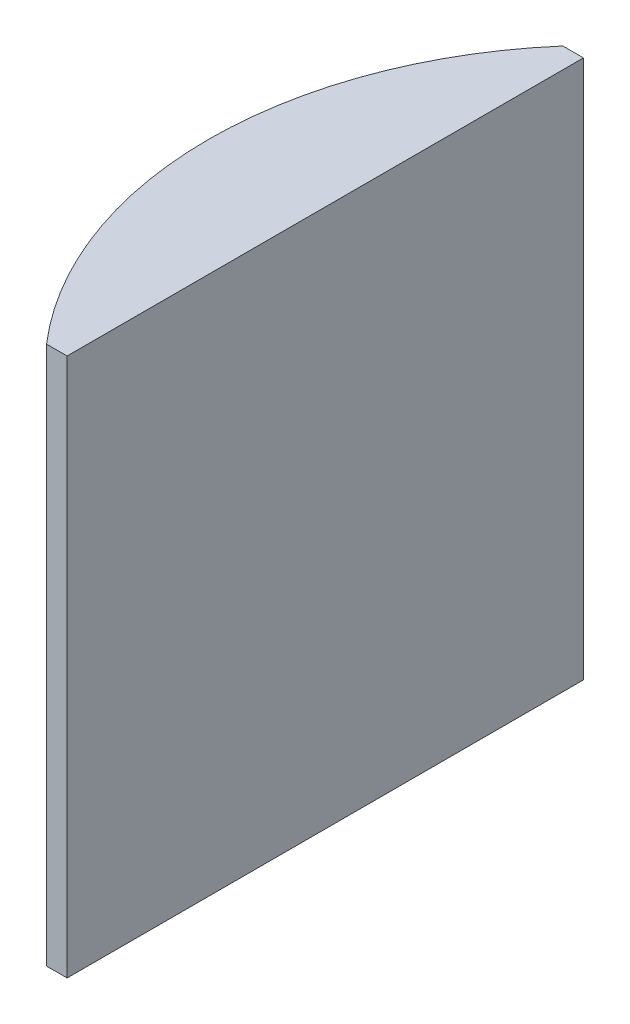
from build123d import *

# Parameters (mm, degrees)
EXTRUDE_1_DEPTH = 53


with BuildPart() as part:
    # 草图1 → 凸台-拉伸1 (new body)
    with BuildSketch(Plane(origin=(0, 0, 0), x_dir=(1, 0, 0), z_dir=(0, 1, 0))):
        with BuildLine():
            Line((-24.948863642, 25.4), (-22.924795665, 25.4))
            Line((-22.924795665, 25.4), (-22.924795665, -25.4))
            Line((-22.924795665, -25.4), (-24.948863642, -25.4))
            ThreePointArc((-24.948863642, -25.4), (-34.424795665, 0), (-24.948863642, 25.4))
        make_face()
    extrude(amount=EXTRUDE_1_DEPTH)


solid = part.part
